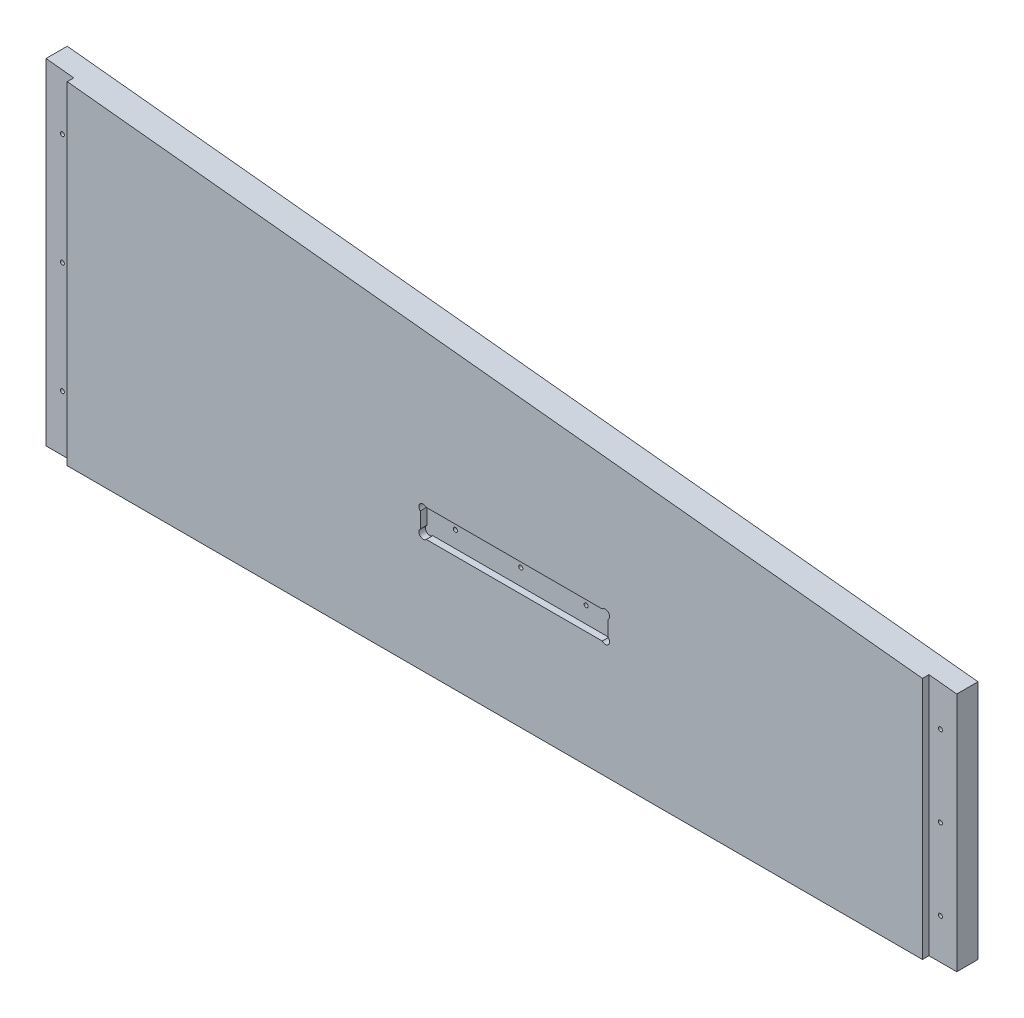
from build123d import *

# Parameters (mm, degrees)
HEADSIDERIGHT_THICKNESS_DEPTH = 21.59
EXTRUDE4_DEPTH                = 16.51
SKETCH8_R                     = 1.5875
CUT_EXTRUDE4_DEPTH            = 21.59
SKETCH9_W                     = 146.050000002
SKETCH9_H                     = 21.59
CUT_EXTRUDE5_DEPTH            = 5.08
SKETCH11_R                    = 3.302
CUT_EXTRUDE6_DEPTH            = 5.08


with BuildPart() as part:
    # HeadSideRightOutline → HeadSideRight_Thickness (new body)
    with BuildSketch(Plane.XY):
        Polygon((174.9425, -6013.45), (839.47, -6013.45), (839.47, -5824.270396825), (174.9425, -5754.954603175), align=None)
    extrude(amount=-HEADSIDERIGHT_THICKNESS_DEPTH)

    # Sketch10 → Extrude4 (add)
    with BuildSketch(Plane(origin=(0, 0, -21.59), x_dir=(-1, 0, 0), z_dir=(0, 0, -1))):
        Polygon((-174.9425, -6013.45), (-153.3525, -6013.45), (-153.3525, -5752.702585034), (-174.9425, -5754.954603175), align=None)
        Polygon((-839.47, -6013.45), (-861.06, -6013.45), (-861.06, -5826.522414966), (-839.47, -5824.270396825), align=None)
    extrude(amount=-EXTRUDE4_DEPTH)

    # Sketch8 → Cut-Extrude4 (cut)
    with BuildSketch(Plane.XY):
        with Locations((166.0525, -5970.212883599)):
            Circle(SKETCH8_R)
        with Locations((166.0525, -5883.738650795)):
            Circle(SKETCH8_R)
        with Locations((166.0525, -5797.264417991)):
            Circle(SKETCH8_R)
        with Locations((848.36, -5982.074616401)):
            Circle(SKETCH8_R)
        with Locations((848.36, -5919.323849205)):
            Circle(SKETCH8_R)
        with Locations((848.36, -5856.573082009)):
            Circle(SKETCH8_R)
        with Locations((471.4875, -5910.834)):
            Circle(SKETCH8_R)
        with Locations((522.2875, -5910.834)):
            Circle(SKETCH8_R)
        with Locations((573.0875, -5910.834)):
            Circle(SKETCH8_R)
    extrude(amount=-CUT_EXTRUDE4_DEPTH, mode=Mode.SUBTRACT)

    # Sketch9 → Cut-Extrude5 (cut)
    with BuildSketch(Plane.XY):
        with Locations((522.2875, -5912.739)):
            Rectangle(SKETCH9_W, SKETCH9_H)
    extrude(amount=-CUT_EXTRUDE5_DEPTH, mode=Mode.SUBTRACT)

    # Sketch11 → Cut-Extrude6 (cut)
    with BuildSketch(Plane.XY):
        with Locations((451.507564029, -5904.18906403)):
            Circle(SKETCH11_R)
        with Locations((451.507564029, -5921.28893597)):
            Circle(SKETCH11_R)
        with Locations((593.067435971, -5921.28893597)):
            Circle(SKETCH11_R)
        with Locations((593.067435971, -5904.18906403)):
            Circle(SKETCH11_R)
    extrude(amount=-CUT_EXTRUDE6_DEPTH, mode=Mode.SUBTRACT)


solid = part.part
